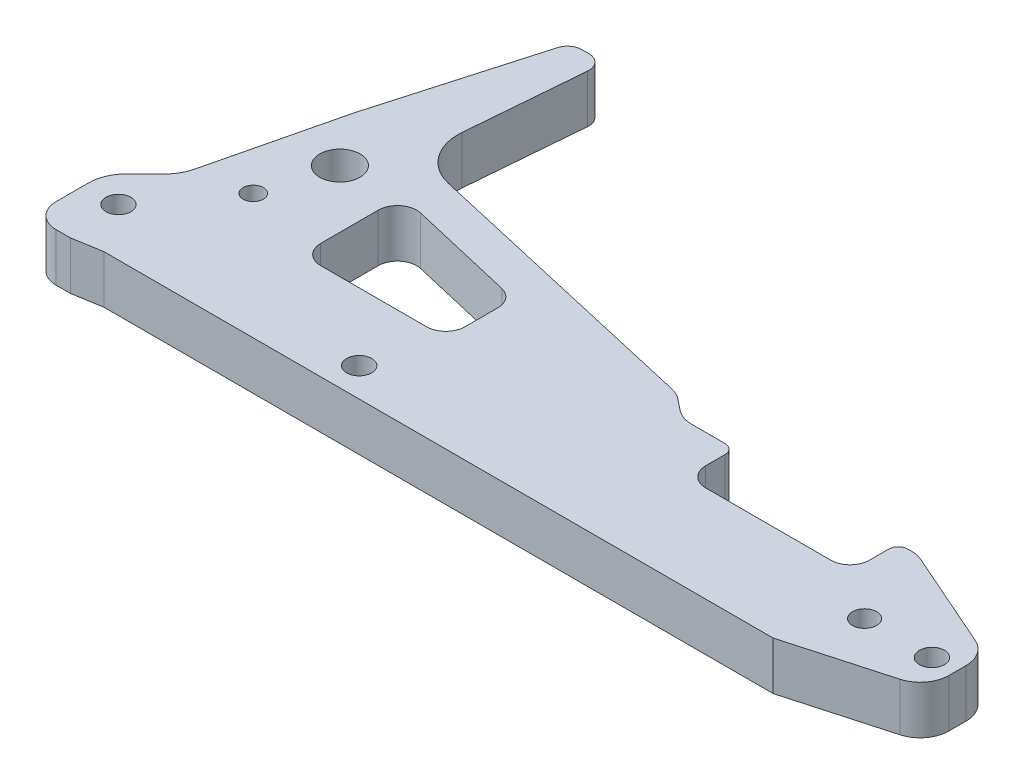
from build123d import *

# Parameters (mm, degrees)
SKETCH1_R           = 2.6
SKETCH1_R_2         = 2.1
SKETCH1_R_3         = 4.2
SKETCH1_R_4         = 2.5
BOSS_EXTRUDE1_DEPTH = 10
FILLET2_R           = 6
FILLET3_R           = 3
CUT_EXTRUDE1_DEPTH  = 11
SKETCH7_R           = 2.6
CUT_EXTRUDE4_DEPTH  = 11
FILLET8_R           = 5
FILLET9_R           = 4
SKETCH10_W          = 34
SKETCH10_H          = 10
CUT_EXTRUDE6_DEPTH  = 11
FILLET10_R          = 4
CUT_EXTRUDE7_DEPTH  = 6
FILLET14_R          = 6
FILLET15_R          = 2
FILLET16_R          = 10
FILLET17_R          = 8
FILLET18_R          = 4
SKETCH13_W          = 35.854861743
SKETCH13_H          = 9
CUT_EXTRUDE8_DEPTH  = 6
FILLET19_R          = 3


with BuildPart() as part:
    # Sketch1 → Boss-Extrude1 (new body)
    with BuildSketch(Plane(origin=(0, 0, 0), x_dir=(1, 0, 0), z_dir=(0, 1, 0))):
        Polygon((164, 19), (139, 30), (90, 30), (85, 34), (15, 50), (18, 86), (11, 86), (1, 51), (-6, 22), (-14, 14), (-14, 2), (-14, -1), (-6, -1), (0, 0), (139, 0), (164, 7), align=None)
        with Locations((-7, 10)):
            Circle(SKETCH1_R, mode=Mode.SUBTRACT)
        with Locations((159, 13)):
            Circle(SKETCH1_R, mode=Mode.SUBTRACT)
        with Locations((5, 26)):
            Circle(SKETCH1_R_2, mode=Mode.SUBTRACT)
        with Locations((9, 40)):
            Circle(SKETCH1_R_3, mode=Mode.SUBTRACT)
        with Locations((145, 13)):
            Circle(SKETCH1_R_4, mode=Mode.SUBTRACT)
    extrude(amount=BOSS_EXTRUDE1_DEPTH)

    # Fillet2
    fillet2_edges = [part.edges().sort_by_distance(p)[0] for p in [
        (139, 5, -30),
        (164, 5, -19),
        (164, 5, -7),
    ]]
    fillet(fillet2_edges, radius=FILLET2_R)

    # Fillet3
    fillet3_edges = [part.edges().sort_by_distance(p)[0] for p in [
        (11, 5, -86),
        (18, 5, -86),
    ]]
    fillet(fillet3_edges, radius=FILLET3_R)

    # Sketch4 → Cut-Extrude1 (cut, through all)
    with BuildSketch(Plane(origin=(0, 10, 0), x_dir=(1, 0, 0), z_dir=(0, 1, 0))):
        Polygon((21, 41), (21, 20), (51, 20), (51, 34), align=None)
    extrude(amount=-CUT_EXTRUDE1_DEPTH, mode=Mode.SUBTRACT)

    # Sketch7 → Cut-Extrude4 (cut, through all)
    with BuildSketch(Plane(origin=(0, 10, 0), x_dir=(1, 0, 0), z_dir=(0, 1, 0))):
        with Locations((47, 6)):
            Circle(SKETCH7_R)
    extrude(amount=-CUT_EXTRUDE4_DEPTH, mode=Mode.SUBTRACT)

    # Fillet8
    fillet8_edges = [part.edges().sort_by_distance(p)[0] for p in [
        (-14, 5, 1),
    ]]
    fillet(fillet8_edges, radius=FILLET8_R)

    # Fillet9
    fillet9_edges = [part.edges().sort_by_distance(p)[0] for p in [
        (21, 5, -41),
        (51, 5, -34),
        (51, 5, -20),
        (21, 5, -20),
    ]]
    fillet(fillet9_edges, radius=FILLET9_R)

    # Sketch10 → Cut-Extrude6 (cut, through all)
    with BuildSketch(Plane(origin=(0, 10, 0), x_dir=(1, 0, 0), z_dir=(0, 1, 0))):
        with Locations((118, 25)):
            Rectangle(SKETCH10_W, SKETCH10_H)
    extrude(amount=-CUT_EXTRUDE6_DEPTH, mode=Mode.SUBTRACT)

    # Fillet10
    fillet10_edges = [part.edges().sort_by_distance(p)[0] for p in [
        (135, 5, -20),
        (101, 5, -20),
    ]]
    fillet(fillet10_edges, radius=FILLET10_R)

    # Sketch12 → Cut-Extrude7 (cut)
    with BuildSketch(Plane(origin=(0, 0, 0), x_dir=(1, 0, 0), z_dir=(0, 1, 0))):
        Polygon((58, 37), (83, 31.034746853), (89, 26.034746853), (89, 14), (58, 14), align=None)
    extrude(amount=CUT_EXTRUDE7_DEPTH, mode=Mode.SUBTRACT)

    # Fillet14
    fillet14_edges = [part.edges().sort_by_distance(p)[0] for p in [
        (85, 5, -34),
        (90, 5, -30),
    ]]
    fillet(fillet14_edges, radius=FILLET14_R)

    # Fillet15
    fillet15_edges = [part.edges().sort_by_distance(p)[0] for p in [
        (101, 5, -30),
        (135, 5, -30),
    ]]
    fillet(fillet15_edges, radius=FILLET15_R)

    # Fillet16
    fillet16_edges = [part.edges().sort_by_distance(p)[0] for p in [
        (15, 5, -50),
    ]]
    fillet(fillet16_edges, radius=FILLET16_R)

    # Fillet17
    fillet17_edges = [part.edges().sort_by_distance(p)[0] for p in [
        (-14, 5, -14),
        (-6, 5, -22),
    ]]
    fillet(fillet17_edges, radius=FILLET17_R)

    # Fillet18
    fillet18_edges = [part.edges().sort_by_distance(p)[0] for p in [
        (58, 3, -37),
        (58, 3, -14),
        (89, 3, -14),
        (89, 3, -26.034746853),
        (83, 3, -31.034746853),
    ]]
    fillet(fillet18_edges, radius=FILLET18_R)

    # Sketch13 → Cut-Extrude8 (cut)
    with BuildSketch(Plane.XZ):
        with Locations((112.927430872, -9.5)):
            Rectangle(SKETCH13_W, SKETCH13_H)
    extrude(amount=-CUT_EXTRUDE8_DEPTH, mode=Mode.SUBTRACT)

    # Fillet19
    fillet19_edges = [part.edges().sort_by_distance(p)[0] for p in [
        (130.854861743, 3, -5),
        (130.854861743, 3, -14),
        (95, 3, -14),
        (95, 3, -5),
    ]]
    fillet(fillet19_edges, radius=FILLET19_R)


solid = part.part
